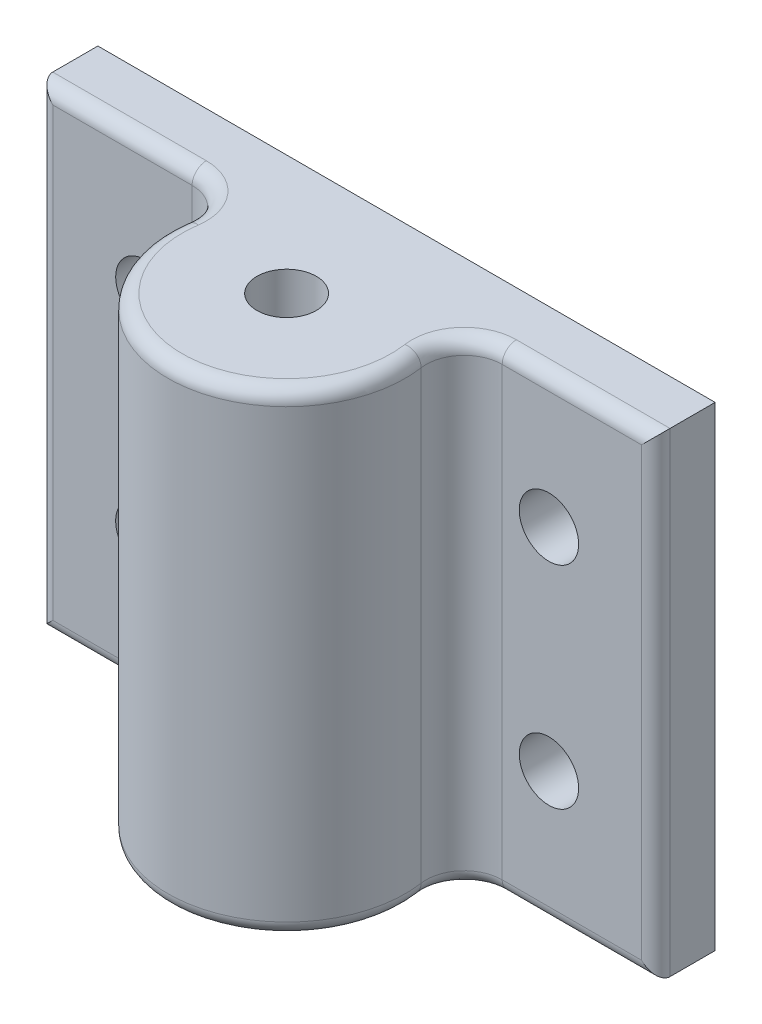
from build123d import *

# Parameters (mm, degrees)
SKETCH1_R           = 6.35
BOSS_EXTRUDE1_DEPTH = 12.7
SKETCH2_W           = 33.02
SKETCH2_H           = 3.175
BOSS_EXTRUDE2_DEPTH = 25.4
CUT_EXTRUDE1_REACH  = 5.175
SKETCH4_R           = 1.5875
SKETCH5_R           = 1.5875
CUT_EXTRUDE2_DEPTH  = 19.05
FILLET2_R           = 2.032
FILLET3_R           = 0.762


with BuildPart() as part:
    # Sketch1 → Boss-Extrude1 (new body, symmetric)
    with BuildSketch(Plane(origin=(0, 0, 0), x_dir=(1, 0, 0), z_dir=(0, 1, 0))):
        Circle(SKETCH1_R)
    extrude(amount=BOSS_EXTRUDE1_DEPTH, both=True)

    # Sketch2 → Boss-Extrude2 (add)
    with BuildSketch(Plane.XZ.offset(12.7)):
        with Locations((0, -4.826)):
            Rectangle(SKETCH2_W, SKETCH2_H)
    extrude(amount=-BOSS_EXTRUDE2_DEPTH)

    # Sketch4 → Cut-Extrude1 (cut, up to next)
    with BuildSketch(Plane.XY.offset(-3.2385), mode=Mode.PRIVATE) as cut_extrude1_sk1:
        with Locations((10.795, 5.6515)):
            Circle(SKETCH4_R)
    cut_extrude1_tool1 = extrude(cut_extrude1_sk1.sketch, amount=-CUT_EXTRUDE1_REACH, mode=Mode.PRIVATE) & part.part
    add(cut_extrude1_tool1.solids().sort_by_distance((10.795, 5.6515, -3.2385))[0], mode=Mode.SUBTRACT)
    # Sketch4 → Cut-Extrude1 (cut, up to next)
    with BuildSketch(Plane.XY.offset(-3.2385), mode=Mode.PRIVATE) as cut_extrude1_sk2:
        with Locations((10.795, -5.6515)):
            Circle(SKETCH4_R)
    cut_extrude1_tool2 = extrude(cut_extrude1_sk2.sketch, amount=-CUT_EXTRUDE1_REACH, mode=Mode.PRIVATE) & part.part
    add(cut_extrude1_tool2.solids().sort_by_distance((10.795, -5.6515, -3.2385))[0], mode=Mode.SUBTRACT)
    # Sketch4 → Cut-Extrude1 (cut, up to next)
    with BuildSketch(Plane.XY.offset(-3.2385), mode=Mode.PRIVATE) as cut_extrude1_sk3:
        with Locations((-10.795, -5.6515)):
            Circle(SKETCH4_R)
    cut_extrude1_tool3 = extrude(cut_extrude1_sk3.sketch, amount=-CUT_EXTRUDE1_REACH, mode=Mode.PRIVATE) & part.part
    add(cut_extrude1_tool3.solids().sort_by_distance((-10.795, -5.6515, -3.2385))[0], mode=Mode.SUBTRACT)
    # Sketch4 → Cut-Extrude1 (cut, up to next)
    with BuildSketch(Plane.XY.offset(-3.2385), mode=Mode.PRIVATE) as cut_extrude1_sk4:
        with Locations((-10.795, 5.6515)):
            Circle(SKETCH4_R)
    cut_extrude1_tool4 = extrude(cut_extrude1_sk4.sketch, amount=-CUT_EXTRUDE1_REACH, mode=Mode.PRIVATE) & part.part
    add(cut_extrude1_tool4.solids().sort_by_distance((-10.795, 5.6515, -3.2385))[0], mode=Mode.SUBTRACT)

    # Sketch5 → Cut-Extrude2 (cut)
    with BuildSketch(Plane(origin=(0, 12.7, 0), x_dir=(1, 0, 0), z_dir=(0, 1, 0))):
        Circle(SKETCH5_R)
    extrude(amount=-CUT_EXTRUDE2_DEPTH, mode=Mode.SUBTRACT)

    # Fillet2
    fillet2_edges = [part.edges().sort_by_distance(p)[0] for p in [
        (-5.462107446, 0, -3.2385),
        (5.462107446, 0, -3.2385),
    ]]
    fillet(fillet2_edges, radius=FILLET2_R)

    # Fillet3
    fillet3_edges = [part.edges().sort_by_distance(p)[0] for p in [
        (12.402357042, -12.7, -3.2385),
        (0, 12.7, 6.35),
        (0, -12.7, 6.35),
        (-12.402357042, 12.7, -3.2385),
        (-12.402357042, -12.7, -3.2385),
        (-6.757939343, -12.7, -2.535916185),
        (-6.757939343, 12.7, -2.535916185),
        (6.757939343, 12.7, -2.535916185),
        (6.757939343, -12.7, -2.535916185),
        (-16.51, 0, -3.2385),
        (12.402357042, 12.7, -3.2385),
        (16.51, 0, -3.2385),
    ]]
    fillet(fillet3_edges, radius=FILLET3_R)


solid = part.part
